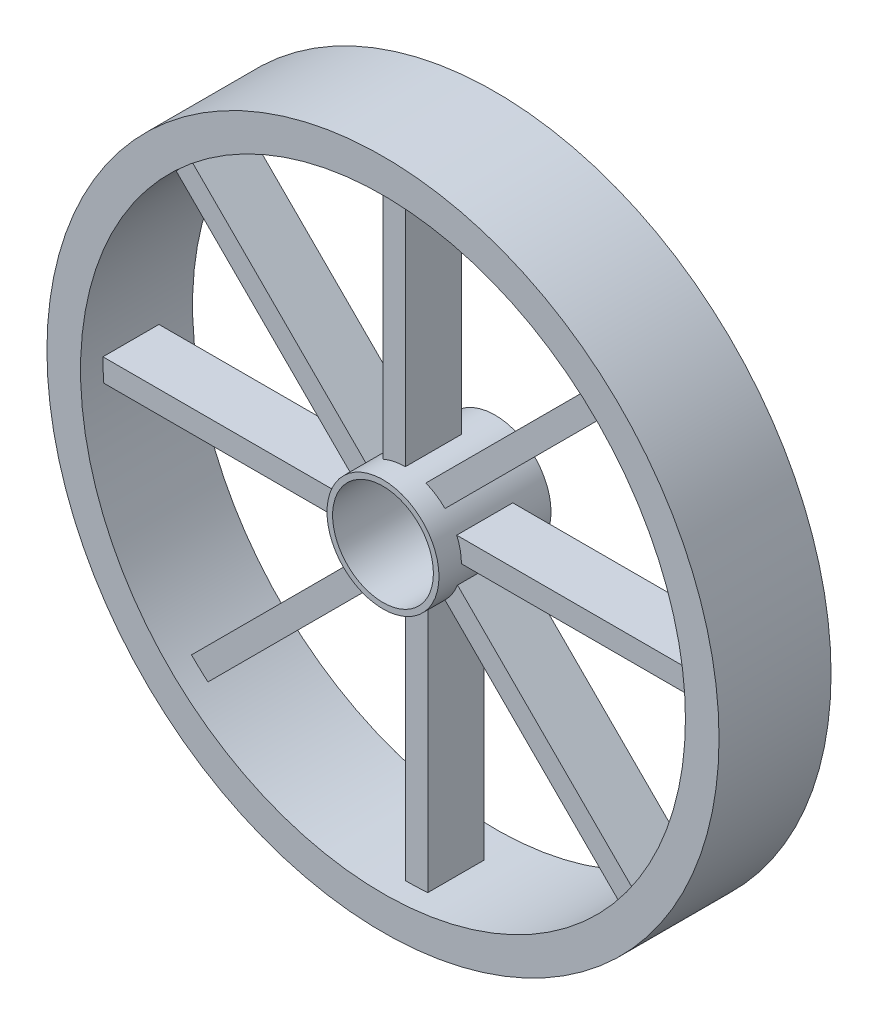
from build123d import *

# Parameters (mm, degrees)
SKETCH2_R             = 30
SKETCH2_R_2           = 27
BOSS_EXTRUDE1_DEPTH   = 10
SKETCH2_R_3           = 5
SKETCH2_R_4           = 4.5
BOSS_EXTRUDE1_2_DEPTH = 10
BOSS_EXTRUDE2_START   = -9
SKETCH4_W             = 5
SKETCH4_H             = 2
BOSS_EXTRUDE2_DEPTH   = 22.417424
CIRPATTERN1_COUNT     = 8


with BuildPart() as part:
    # Sketch2 → Boss-Extrude1 (new body)
    with BuildSketch(Plane.XY):
        Circle(SKETCH2_R)
        Circle(SKETCH2_R_2, mode=Mode.SUBTRACT)
    extrude(amount=BOSS_EXTRUDE1_DEPTH)



with BuildPart() as body_2:
    # Sketch2 → Boss-Extrude1 2 (new body)
    with BuildSketch(Plane.XY):
        Circle(SKETCH2_R_3)
        Circle(SKETCH2_R_4, mode=Mode.SUBTRACT)
    extrude(amount=BOSS_EXTRUDE1_2_DEPTH)


with BuildPart() as part_1:
    add(part.part)

    add(body_2.part)  # Boss-Extrude2 merges body 2
    # Sketch4 → Boss-Extrude2 (add)
    with BuildSketch(Plane(origin=(-18, 0, 0), x_dir=(0, 0, -1), z_dir=(1, 0, 0)).offset(BOSS_EXTRUDE2_START)):
        with Locations((-5.5, -1)):
            Rectangle(SKETCH4_W, SKETCH4_H)
    boss_extrude2 = extrude(amount=BOSS_EXTRUDE2_DEPTH)

    # CirPattern1: Boss-Extrude2 ×8 about axis
    cirpattern1_axis = Axis((0, 0, 0), (0, 0, 1))
    for i in range(1, CIRPATTERN1_COUNT):
        add(boss_extrude2.rotate(cirpattern1_axis, i * 360 / CIRPATTERN1_COUNT))


solid = part_1.part
